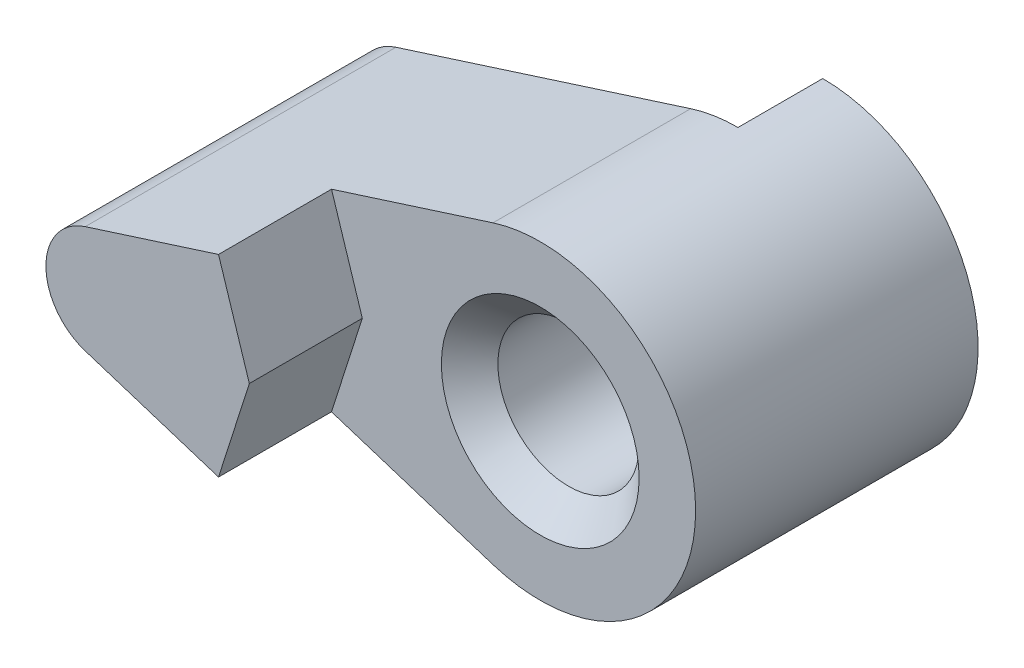
from build123d import *

# Parameters (mm, degrees)
ESQUISSE1_R             = 2.5
EXTRUSION1_DEPTH        = 14
ENL_V_MAT_EXTRU_1_DEPTH = 4
ESQUISSE4_R             = 2.5
ENL_V_MAT_EXTRU_2_DEPTH = 3
CHANFREIN1_SIZE         = 1


with BuildPart() as part:
    # Esquisse1 → Extrusion1 (new body)
    with BuildSketch(Plane.XY):
        with BuildLine():
            Line((-1.673913043, 5.239085333), (-12.108695652, 1.905121939))
            ThreePointArc((-12.108695652, 1.905121939), (-13.5, 0), (-12.108695652, -1.905121939))
            Line((-12.108695652, -1.905121939), (-1.673913043, -5.239085333))
            ThreePointArc((-1.673913043, -5.239085333), (5.5, 0), (-1.673913043, 5.239085333))
        make_face()
        Circle(ESQUISSE1_R, mode=Mode.SUBTRACT)
    extrude(amount=EXTRUSION1_DEPTH)

    # Esquisse2 → Enlèv. mat.-Extru.1 (cut)
    with BuildSketch(Plane.XY.offset(14)):
        with BuildLine():
            Line((-1.673913043, 5.239085333), (-7.389278861, 3.412998376))
            Line((-7.389278861, 3.412998376), (-6.298809411, 0))
            Line((-6.298809411, 0), (-7.389278861, -3.412998376))
            Line((-7.389278861, -3.412998376), (-1.673913043, -5.239085333))
            ThreePointArc((-1.673913043, -5.239085333), (5.5, 0), (-1.673913043, 5.239085333))
        make_face()
    extrude(amount=-ENL_V_MAT_EXTRU_1_DEPTH, mode=Mode.SUBTRACT)

    # Esquisse4 → Enlèv. mat.-Extru.2 (cut)
    with BuildSketch(Plane(origin=(0, 0, 0), x_dir=(-1, 0, 0), z_dir=(0, 0, -1))):
        with Locations(Location((0, 0, 0), (0, 0, 102.45923378))):  # turned: the seam where the file's is
            Circle(ESQUISSE4_R)
        with BuildLine():
            Line((1.673913043, -5.239085333), (12.108695652, -1.905121939))
            ThreePointArc((12.108695652, -1.905121939), (13.5, 0), (12.108695652, 1.905121939))
            Line((12.108695652, 1.905121939), (1.673913043, 5.239085333))
            ThreePointArc((1.673913043, 5.239085333), (0.847062769, 5.434379879), (0, 5.5))
            Line((0, 5.5), (-1.881110788, -5.168309414))
            ThreePointArc((-1.881110788, -5.168309414), (-0.10947618, -5.498910344), (1.673913043, -5.239085333))
        make_face()
    extrude(amount=-ENL_V_MAT_EXTRU_2_DEPTH, mode=Mode.SUBTRACT)

    # Chanfrein1
    chanfrein1_edges = [part.edges().sort_by_distance(p)[0] for p in [
        (-2.5, 0, 10),
    ]]
    chamfer(chanfrein1_edges, length=CHANFREIN1_SIZE)


solid = part.part
